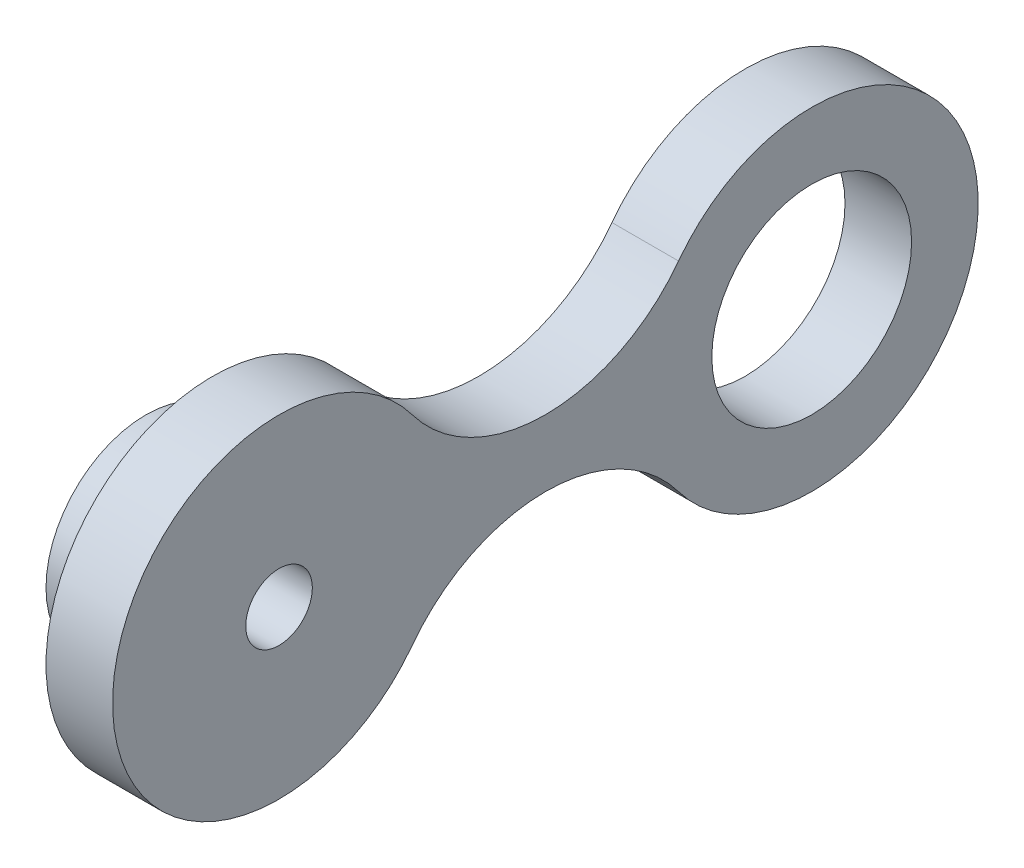
from build123d import *

# Parameters (mm, degrees)
SKETCH1_R           = 15
BOSS_EXTRUDE1_DEPTH = 10
SKETCH2_R           = 15
BOSS_EXTRUDE2_DEPTH = 10
SKETCH3_R           = 15
BOSS_EXTRUDE3_DEPTH = 10
SKETCH4_R           = 5
CUT_EXTRUDE1_DEPTH  = 36


with BuildPart() as part:
    # Sketch1 → Boss-Extrude1 (new body)
    with BuildSketch(Plane(origin=(0, 0, 0), x_dir=(0, 0, -1), z_dir=(1, 0, 0))):
        with BuildLine():
            ThreePointArc((20, 15), (-25, 0), (20, -15))
            ThreePointArc((20, -15), (40, -5), (60, -15))
            ThreePointArc((60, -15), (105, 0), (60, 15))
            ThreePointArc((60, 15), (40, 5), (20, 15))
        make_face()
        Circle(SKETCH1_R, mode=Mode.SUBTRACT)
        with Locations((80, 0)):
            Circle(SKETCH1_R, mode=Mode.SUBTRACT)
    extrude(amount=BOSS_EXTRUDE1_DEPTH)

    # Sketch2 → Boss-Extrude2 (add)
    with BuildSketch(Plane.ZY):
        Circle(SKETCH2_R)
    extrude(amount=-BOSS_EXTRUDE2_DEPTH)

    # Sketch3 → Boss-Extrude3 (add)
    with BuildSketch(Plane.ZY):
        Circle(SKETCH3_R)
    extrude(amount=BOSS_EXTRUDE3_DEPTH)

    # Sketch4 → Cut-Extrude1 (cut)
    with BuildSketch(Plane.ZY.offset(10)):
        Circle(SKETCH4_R)
    extrude(amount=-CUT_EXTRUDE1_DEPTH, mode=Mode.SUBTRACT)


solid = part.part
